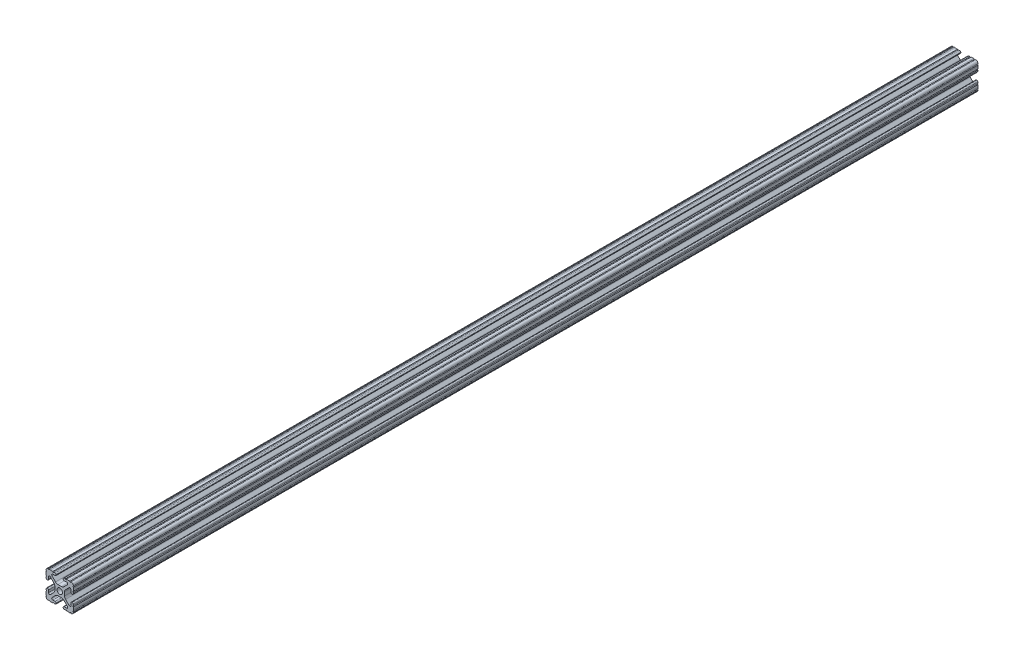
from build123d import *

# Parameters (mm, degrees)
SKETCH1_R      = 2.5527
EXTRUDE1_DEPTH = 838.2


with BuildPart() as part:
    # Sketch1 → Extrude1 (new body)
    with BuildSketch(Plane.XY):
        with BuildLine():
            Line((25.433443131, 2.149221002), (25.433433122, 2.132304602))
            ThreePointArc((25.433433122, 2.132304602), (24.81352977, 0.635652711), (23.316920529, 0.0156464))
            Line((23.316920529, 0.0156464), (23.300004129, 0.015621))
            ThreePointArc((23.300004129, 0.015621), (22.791978729, 0.518591735), (22.283953329, 0.015621))
            Line((22.283953329, 0.015621), (21.200262329, 0.015621))
            Line((21.200262329, 0.015621), (19.066357529, 0.0901446))
            ThreePointArc((19.066357529, 0.0901446), (18.57651791, 0.619499034), (18.050946389, 0.125602744))
            Line((18.050946389, 0.125602744), (16.985183129, 0.1812798))
            ThreePointArc((16.985183129, 0.1812798), (16.266656931, 0.501228728), (15.972027929, 1.230503))
            Line((15.972027929, 1.230503), (15.972002529, 1.330908925))
            ThreePointArc((15.972002529, 1.330908925), (16.292567692, 2.086113746), (17.058499831, 2.380127869))
            Line((17.058499831, 2.380127869), (19.115070367, 2.28984489))
            ThreePointArc((19.115070367, 2.28984489), (20.109237927, 2.946078438), (19.79674691, 4.095583101))
            Line((19.79674691, 4.095583101), (16.602495326, 7.289892083))
            ThreePointArc((16.602495326, 7.289892083), (15.5724442, 7.978160281), (14.357411125, 8.219848224))
            Line((14.357411125, 8.219848224), (12.733578665, 8.219848224))
            Line((12.733578665, 8.219848224), (11.109350265, 8.219848224))
            ThreePointArc((11.109350265, 8.219848224), (9.894326313, 7.97816406), (8.864280029, 7.289906048))
            Line((8.864280029, 7.289906048), (5.670118065, 4.095726424))
            ThreePointArc((5.670118065, 4.095726424), (5.357454926, 2.946), (6.351985959, 2.289846732))
            Line((6.351985959, 2.289846732), (8.408555268, 2.380129669))
            ThreePointArc((8.408555268, 2.380129669), (9.174487549, 2.086116104), (9.495053265, 1.330911592))
            Line((9.495053265, 1.330911592), (9.495078665, 1.230505007))
            ThreePointArc((9.495078665, 1.230505007), (9.200425317, 0.501212103), (8.481859988, 0.181286169))
            Line((8.481859988, 0.181286169), (7.416109406, 0.125604568))
            ThreePointArc((7.416109406, 0.125604568), (6.890689076, 0.615566134), (6.400728384, 0.090144989))
            Line((6.400728384, 0.090144989), (4.266844329, 0.015621))
            Line((4.266844329, 0.015621), (3.183051729, 0.015621))
            ThreePointArc((3.183051729, 0.015621), (2.675064429, 0.52002892), (2.167077129, 0.015621))
            Line((2.167077129, 0.015621), (2.150186129, 0.015621))
            ThreePointArc((2.150186129, 0.015621), (0.653473782, 0.635584814), (0.033527929, 2.1323046))
            Line((0.033527929, 2.1323046), (0.033502529, 2.149221))
            ThreePointArc((0.033502529, 2.149221), (0.541502529, 2.657221), (0.033502529, 3.165221))
            Line((0.033502529, 3.165221), (0.033502529, 4.2489628))
            Line((0.033502529, 4.2489628), (0.108051389, 6.382893005))
            ThreePointArc((0.108051389, 6.382893005), (0.636769546, 6.872740923), (0.143484067, 7.398253347))
            Line((0.143484067, 7.398253347), (0.199186453, 8.463965811))
            ThreePointArc((0.199186453, 8.463965811), (0.519108205, 9.182539461), (1.248405666, 9.47719728))
            Line((1.248405666, 9.47719728), (1.348815787, 9.477273486))
            ThreePointArc((1.348815787, 9.477273486), (2.104048619, 9.15668186), (2.398034533, 8.3907002))
            Line((2.398034533, 8.3907002), (2.307726292, 6.334129777))
            ThreePointArc((2.307726292, 6.334129777), (2.917959272, 5.36690304), (4.041530045, 5.580211665))
            Line((4.041530045, 5.580211665), (7.299319478, 8.838034664))
            ThreePointArc((7.299319478, 8.838034664), (7.987564527, 9.868074786), (8.229243882, 11.083087128))
            Line((8.229243882, 11.083087128), (8.229243882, 12.715595928))
            Line((8.229243882, 12.715595928), (8.229243882, 14.348182637))
            ThreePointArc((8.229243882, 14.348182637), (7.987566856, 15.563189358), (7.299328083, 16.593226497))
            Line((7.299328083, 16.593226497), (4.041535389, 19.85107773))
            ThreePointArc((4.041535389, 19.85107773), (2.917975571, 20.06439507), (2.307727974, 19.09718836))
            Line((2.307727974, 19.09718836), (2.398036312, 17.040593596))
            ThreePointArc((2.398036312, 17.040593596), (2.10402253, 16.274661146), (1.348817665, 15.954095654))
            Line((1.348817665, 15.954095654), (1.248411465, 15.954095654))
            ThreePointArc((1.248411465, 15.954095654), (0.519124814, 16.248743141), (0.199193406, 16.967297282))
            Line((0.199193406, 16.967297282), (0.14348581, 18.033064914))
            ThreePointArc((0.14348581, 18.033064914), (0.63344738, 18.558485131), (0.108026456, 19.048445943))
            Line((0.108026456, 19.048445943), (0.033502529, 21.1823554))
            Line((0.033502529, 21.1823554), (0.033502529, 22.2660972))
            ThreePointArc((0.033502529, 22.2660972), (0.545094609, 22.7740845), (0.033502529, 23.2820718))
            Line((0.033502529, 23.2820718), (0.033502529, 23.298997075))
            ThreePointArc((0.033502529, 23.298997075), (0.653448354, 24.795691433), (2.15013525, 25.415655275))
            Line((2.15013525, 25.415655275), (2.167093654, 25.415629946))
            ThreePointArc((2.167093654, 25.415629946), (2.675083099, 24.904039996), (3.183068254, 25.415634206))
            Line((3.183068254, 25.415634206), (4.266835454, 25.415634206))
            Line((4.266835454, 25.415634206), (6.400740254, 25.341136006))
            ThreePointArc((6.400740254, 25.341136006), (6.890804215, 24.818958649), (7.416100594, 25.305677862))
            Line((7.416100594, 25.305677862), (8.481838454, 25.250000806))
            ThreePointArc((8.481838454, 25.250000806), (9.200412021, 24.930079072), (9.495069854, 24.200781707))
            Line((9.495069854, 24.200781707), (9.495069854, 24.100371406))
            ThreePointArc((9.495069854, 24.100371406), (9.174504645, 23.345166815), (8.408572699, 23.051152732))
            Line((8.408572699, 23.051152732), (6.352002282, 23.141435707))
            ThreePointArc((6.352002282, 23.141435707), (5.384806579, 22.531184689), (5.598121123, 21.407631959))
            Line((5.598121123, 21.407631959), (7.697410254, 19.308356606))
            Line((7.697410254, 19.308356606), (8.864372763, 18.141401758))
            ThreePointArc((8.864372763, 18.141401758), (9.894414341, 17.453153646), (11.109429425, 17.211473156))
            Line((11.109429425, 17.211473156), (12.733581625, 17.211473156))
            Line((12.733581625, 17.211473156), (14.357534054, 17.211473156))
            ThreePointArc((14.357534054, 17.211473156), (15.572561508, 17.45315877), (16.60260965, 18.141420692))
            Line((16.60260965, 18.141420692), (19.796856475, 21.335700428))
            ThreePointArc((19.796856475, 21.335700428), (20.109338963, 22.485254296), (19.115085927, 23.141440475))
            Line((19.115085927, 23.141440475), (17.057348777, 23.051157558))
            ThreePointArc((17.057348777, 23.051157558), (16.291416105, 23.345171208), (15.970850487, 24.100376193))
            Line((15.970850487, 24.100376193), (15.970850487, 24.200756993))
            ThreePointArc((15.970850487, 24.200756993), (16.265496714, 24.930042339), (16.98404849, 25.249974926))
            Line((16.98404849, 25.249974926), (18.050937347, 25.305682649))
            ThreePointArc((18.050937347, 25.305682649), (18.576354433, 24.815720969), (19.066318594, 25.341135742))
            Line((19.066318594, 25.341135742), (21.200253454, 25.415634206))
            Line((21.200253454, 25.415634206), (22.283969854, 25.415634206))
            ThreePointArc((22.283969854, 25.415634206), (22.791957154, 24.904042126), (23.299944454, 25.415634206))
            Line((23.299944454, 25.415634206), (23.316930297, 25.415634206))
            ThreePointArc((23.316930297, 25.415634206), (24.813629353, 24.795683684), (25.433588497, 23.2989882))
            Line((25.433588497, 23.2989882), (25.433613897, 23.2820718))
            ThreePointArc((25.433613897, 23.2820718), (24.925618902, 22.774071644), (25.43361421, 22.2660718))
            Line((25.43361421, 22.2660718), (25.4336042, 21.1823554))
            Line((25.4336042, 21.1823554), (25.3590552, 19.048476))
            ThreePointArc((25.3590552, 19.048476), (24.826095097, 18.558846649), (25.323514364, 18.033149546))
            Line((25.323514364, 18.033149546), (25.267781506, 16.967386543))
            ThreePointArc((25.267781506, 16.967386543), (24.947855109, 16.248812971), (24.21855381, 15.954159797))
            ThreePointArc((24.21855381, 15.954159797), (23.396859234, 16.236195338), (23.068959156, 17.040687453))
            Line((23.068959156, 17.040687453), (23.159251265, 19.097257735))
            ThreePointArc((23.159251265, 19.097257735), (22.549002581, 20.064456727), (21.425448036, 19.851143506))
            Line((21.425448036, 19.851143506), (18.167765516, 16.593442973))
            ThreePointArc((18.167765516, 16.593442973), (17.479516557, 15.563400992), (17.237835752, 14.348385149))
            Line((17.237835752, 14.348385149), (17.237835752, 12.715636694))
            Line((17.237835752, 12.715636694), (17.237835752, 11.083127894))
            ThreePointArc((17.237835752, 11.083127894), (17.47952023, 9.868103183), (18.16777909, 8.838056496))
            Line((18.16777909, 8.838056496), (21.353523773, 5.652332724))
            ThreePointArc((21.353523773, 5.652332724), (22.503190772, 5.339700837), (23.159374985, 6.334132928))
            Line((23.159374985, 6.334132928), (23.069082951, 8.390722922))
            ThreePointArc((23.069082951, 8.390722922), (23.363090217, 9.15665763), (24.118292102, 9.477229556))
            Line((24.118292102, 9.477229556), (24.218677373, 9.477255408))
            ThreePointArc((24.218677373, 9.477255408), (24.94789253, 9.182528501), (25.267744306, 8.463978895))
            Line((25.267744306, 8.463978895), (25.323466772, 7.398253367))
            ThreePointArc((25.323466772, 7.398253367), (24.833515373, 6.872829664), (25.358933799, 6.382872606))
            Line((25.358933799, 6.382872606), (25.43344779, 4.248962801))
            Line((25.43344779, 4.248962801), (25.43343778, 3.165221001))
            ThreePointArc((25.43343778, 3.165221001), (24.925433088, 2.657218326), (25.433443131, 2.149221002))
        make_face()
        with Locations((12.7335534, 12.7156464)):
            Circle(SKETCH1_R, mode=Mode.SUBTRACT)
    extrude(amount=-EXTRUDE1_DEPTH)


solid = part.part
